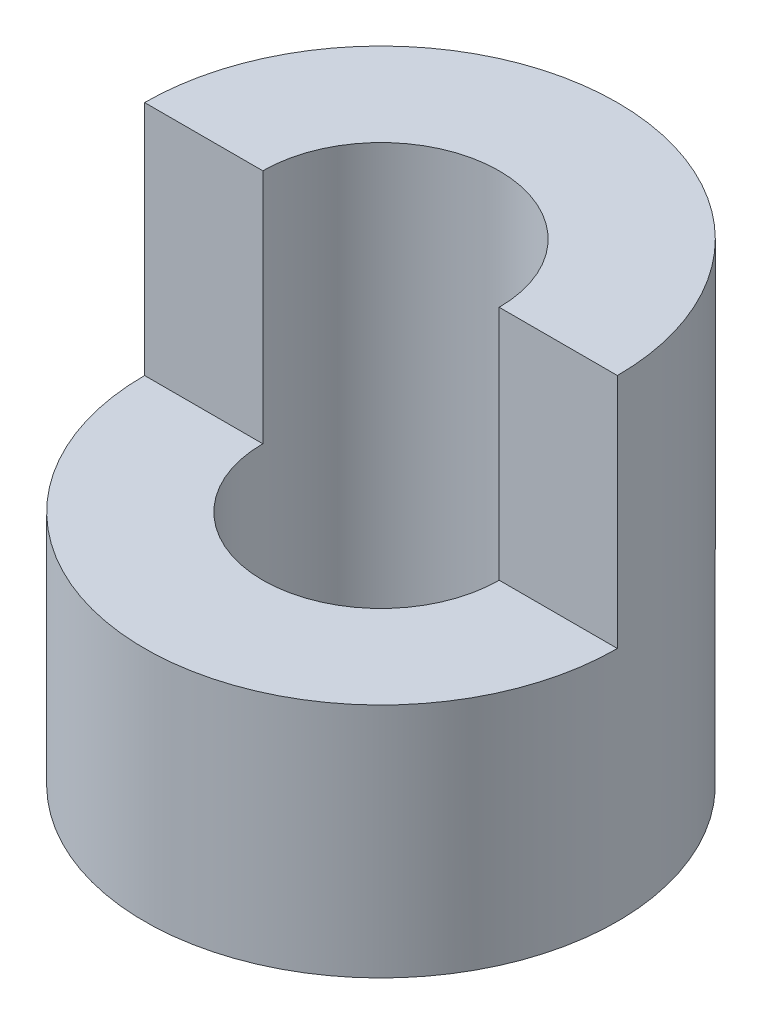
from build123d import *

# Parameters (mm, degrees)
SKETCH1_W          = 10
SKETCH1_H          = 20
SKETCH2_R          = 5
CUT_EXTRUDE1_DEPTH = 20
CUT_EXTRUDE2_DEPTH = 10


with BuildPart() as part:
    # Sketch1 → Revolve1 (revolve)
    with BuildSketch(Plane.XY):
        with Locations((5, 10)):
            Rectangle(SKETCH1_W, SKETCH1_H)
    revolve(axis=Axis((0, 0, 0), (0, 1, 0)))

    # Sketch2 → Cut-Extrude1 (cut)
    with BuildSketch(Plane(origin=(0, 20, 0), x_dir=(1, 0, 0), z_dir=(0, 1, 0))):
        Circle(SKETCH2_R)
    extrude(amount=-CUT_EXTRUDE1_DEPTH, mode=Mode.SUBTRACT)

    # Sketch3 → Cut-Extrude2 (cut)
    with BuildSketch(Plane(origin=(0, 20, 0), x_dir=(1, 0, 0), z_dir=(0, 1, 0))):
        with BuildLine():
            Line((-10, 0), (-5, 0))
            ThreePointArc((-5, 0), (0, -5), (5, 0))
            Line((5, 0), (10, 0))
            ThreePointArc((10, 0), (0, -10), (-10, 0))
        make_face()
    extrude(amount=-CUT_EXTRUDE2_DEPTH, mode=Mode.SUBTRACT)


solid = part.part
